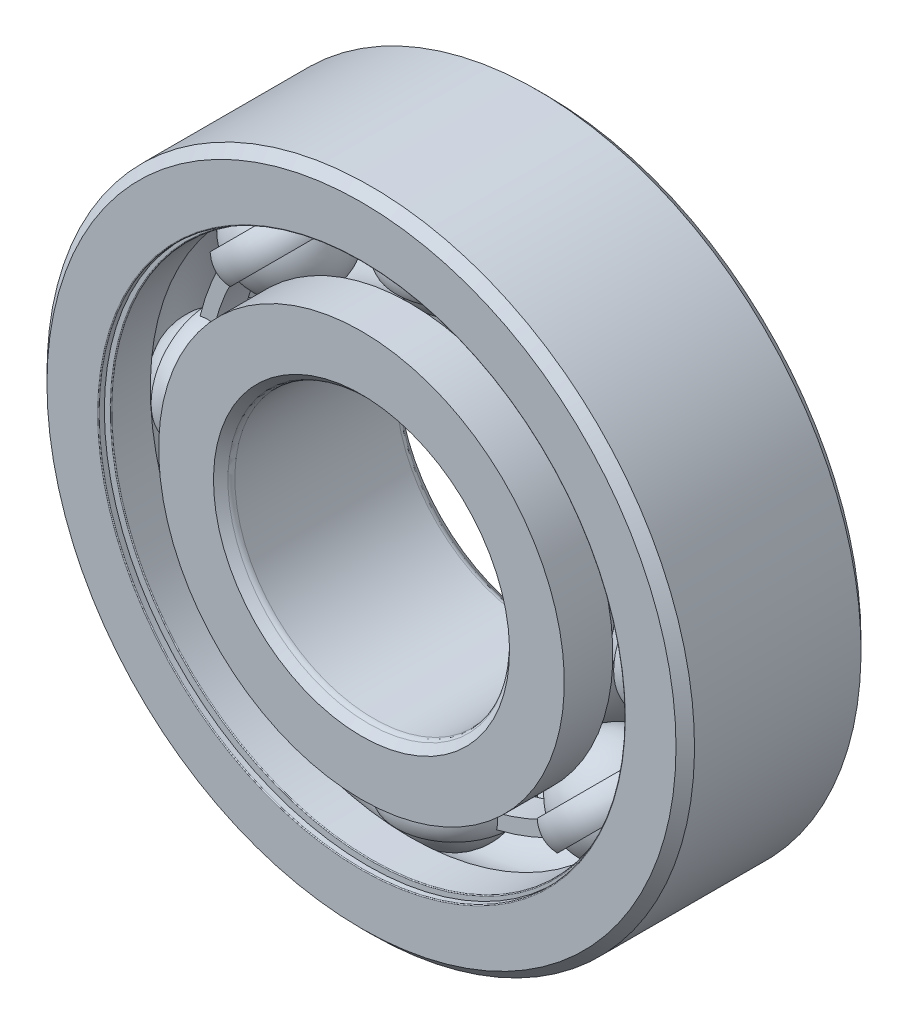
from build123d import *

# Parameters (mm, degrees)
BOSS_EXTRUDE1_DEPTH = 0.666666667
CIRPATTERN1_COUNT   = 8
CIRPATTERN2_COUNT   = 8
FILLET1_R           = 0.036
FILLET2_R           = 0.3


with BuildPart() as part:
    # Sketch3 → Revolve1 (revolve)
    with BuildSketch(Plane(origin=(0, 0, 0), x_dir=(0, 0, -1), z_dir=(1, 0, 0))):
        with BuildLine():
            Line((3.6, 14), (4, 13.6))
            Line((4, 13.6), (4, 11.230769231))
            Line((4, 11.230769231), (1.9, 11.230769231))
            ThreePointArc((1.9, 11.230769231), (0, 12.263800543), (-1.9, 11.230769231))
            Line((-1.9, 11.230769231), (-4, 11.230769231))
            Line((-4, 11.230769231), (-4, 13.6))
            Line((-4, 13.6), (-3.6, 14))
            Line((-3.6, 14), (3.6, 14))
        make_face()
    revolve(axis=Axis((0, 0, 4), (0, 0, -1)))

    # Sketch8 → Cut-Revolve1 (revolve, cut)
    with BuildSketch(Plane(origin=(0, 0, 0), x_dir=(0, 0, -1), z_dir=(1, 0, 0))):
        Polygon((-3.744, 11.230769231), (-3.6, 11.230769231), (-3.6, 12.153846154), (-3.744, 12.153846154), (-3.744, 11.374769231), (-4, 11.374769231), (-4, 11.230769231), align=None)
        Polygon((3.6, 11.230769231), (3.744, 11.230769231), (4, 11.230769231), (4, 11.374769231), (3.744, 11.374769231), (3.744, 12.153846154), (3.6, 12.153846154), align=None)
    revolve(axis=Axis((0, 0, 4), (0, 0, -1)), mode=Mode.SUBTRACT)

    # Fillet1
    fillet1_edges = [part.edges().sort_by_distance(p)[0] for p in [
        (0, -11.374769231, 4),
        (0, -11.230769231, 3.6),
        (0, -11.374769231, -4),
        (0, -11.230769231, -3.6),
    ]]
    fillet(fillet1_edges, radius=FILLET1_R)


with BuildPart() as body_2:
    # Sketch4 → Revolve2 (revolve)
    with BuildSketch(Plane(origin=(0, 0, 0), x_dir=(0, 0, -1), z_dir=(1, 0, 0))):
        with BuildLine():
            Line((-3.6, 6), (-4, 6.4))
            Line((-4, 6.4), (-4, 8.769230769))
            Line((-4, 8.769230769), (-1.9, 8.769230769))
            ThreePointArc((-1.9, 8.769230769), (0, 7.736199457), (1.9, 8.769230769))
            Line((1.9, 8.769230769), (4, 8.769230769))
            Line((4, 8.769230769), (4, 6.4))
            Line((4, 6.4), (3.6, 6))
            Line((3.6, 6), (-3.6, 6))
        make_face()
    revolve(axis=Axis((0, 0, 4), (0, 0, -1)))

    # Fillet2
    fillet2_edges = [body_2.edges().sort_by_distance(p)[0] for p in [
        (0, -6, 3.6),
        (0, -6, -3.6),
    ]]
    fillet(fillet2_edges, radius=FILLET2_R)


with BuildPart() as body_3:
    # Sketch5 → Revolve3 (revolve)
    with BuildSketch(Plane(origin=(0, 0, 0), x_dir=(0, 0, -1), z_dir=(1, 0, 0))):
        with BuildLine():
            Line((-2.263800543, 10), (2.263800543, 10))
            ThreePointArc((2.263800543, 10), (0, 12.263800543), (-2.263800543, 10))
        make_face()
    revolve(axis=Axis((0, 10, 2.263800543), (0, 0, -1)))


with BuildPart() as body_4:
    # Sketch6 → Revolve4 (revolve)
    with BuildSketch(Plane(origin=(0, 0, 0), x_dir=(0, 0, -1), z_dir=(1, 0, 0))):
        with BuildLine():
            Line((-2.178553344, 10.615384615), (-2.482127787, 10.615384615))
            ThreePointArc((-2.482127787, 10.615384615), (-2.633915008, 10), (-2.482127787, 9.384615385))
            Line((-2.482127787, 9.384615385), (-2.178553344, 9.384615385))
            ThreePointArc((-2.178553344, 9.384615385), (-2.263800543, 10), (-2.178553344, 10.615384615))
        make_face()
    revolve4 = revolve(axis=Axis((0, 14, 0), (0, -1, 0)))

    # Sketch7 → Boss-Extrude1 (add, symmetric)
    with BuildSketch(Plane.XY):
        with BuildLine():
            Line((7.071067812, 7.071067812), (7.506210446, 7.506210446))
            ThreePointArc((7.506210446, 7.506210446), (4.06233182, 9.807336576), (0, 10.615384615))
            Line((0, 10.615384615), (0, 10))
            ThreePointArc((0, 10), (3.826834324, 9.238795325), (7.071067812, 7.071067812))
        make_face()
    boss_extrude1 = extrude(amount=BOSS_EXTRUDE1_DEPTH, both=True)

    # CirPattern2: Revolve4, Boss-Extrude1 ×8 about axis
    cirpattern2_axis = Axis((0, 0, 0), (0, 0, 1))
    for i in range(1, CIRPATTERN2_COUNT):
        add(revolve4.rotate(cirpattern2_axis, i * 360 / CIRPATTERN2_COUNT))
        add(boss_extrude1.rotate(cirpattern2_axis, i * 360 / CIRPATTERN2_COUNT))


with BuildPart() as cirpattern1_1:
    # CirPattern1: pattern copy
    add(body_3.part.rotate(Axis((0, 0, 0), (0, 0, 1)), 1 * 360 / CIRPATTERN1_COUNT))


with BuildPart() as cirpattern1_2:
    # CirPattern1: pattern copy
    add(body_3.part.rotate(Axis((0, 0, 0), (0, 0, 1)), 2 * 360 / CIRPATTERN1_COUNT))


with BuildPart() as cirpattern1_3:
    # CirPattern1: pattern copy
    add(body_3.part.rotate(Axis((0, 0, 0), (0, 0, 1)), 3 * 360 / CIRPATTERN1_COUNT))


with BuildPart() as cirpattern1_4:
    # CirPattern1: pattern copy
    add(body_3.part.rotate(Axis((0, 0, 0), (0, 0, 1)), 4 * 360 / CIRPATTERN1_COUNT))


with BuildPart() as cirpattern1_5:
    # CirPattern1: pattern copy
    add(body_3.part.rotate(Axis((0, 0, 0), (0, 0, 1)), 5 * 360 / CIRPATTERN1_COUNT))


with BuildPart() as cirpattern1_6:
    # CirPattern1: pattern copy
    add(body_3.part.rotate(Axis((0, 0, 0), (0, 0, 1)), 6 * 360 / CIRPATTERN1_COUNT))


with BuildPart() as cirpattern1_7:
    # CirPattern1: pattern copy
    add(body_3.part.rotate(Axis((0, 0, 0), (0, 0, 1)), 7 * 360 / CIRPATTERN1_COUNT))


solid = Compound([part.part, body_2.part, body_3.part, body_4.part, cirpattern1_1.part, cirpattern1_2.part, cirpattern1_3.part, cirpattern1_4.part, cirpattern1_5.part, cirpattern1_6.part, cirpattern1_7.part])
